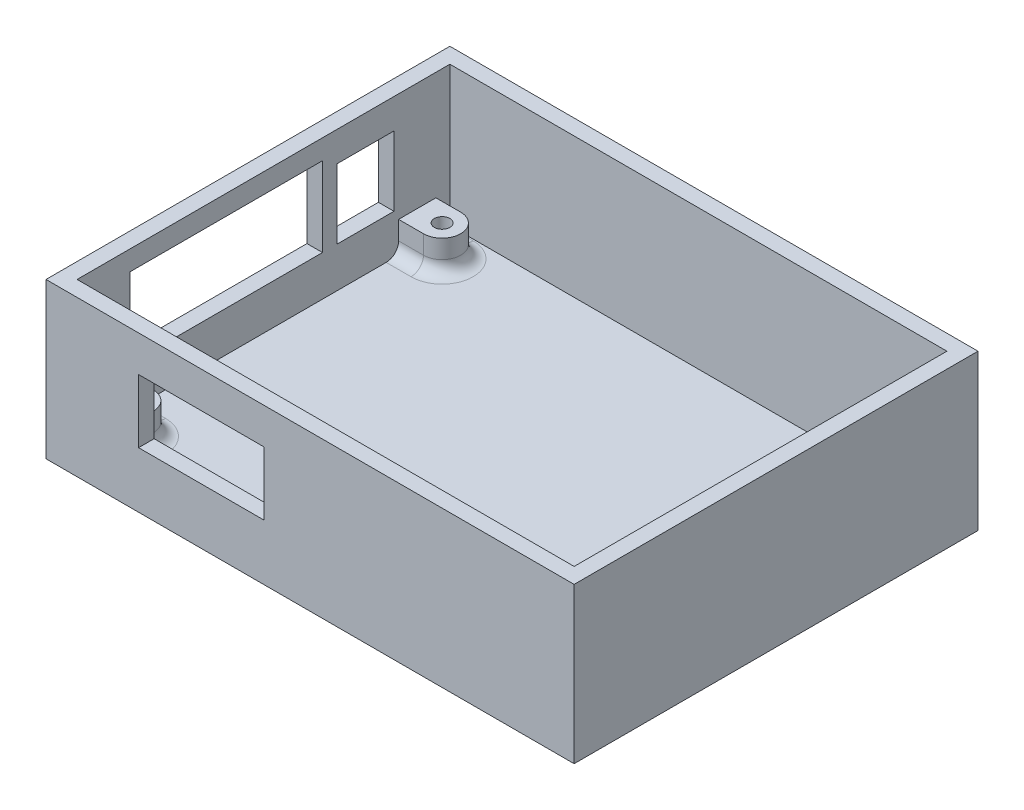
from build123d import *

# Parameters (mm, degrees)
SKETCH_1_W          = 85
SKETCH_1_H          = 65
EXTRUDE_1_DEPTH     = 25
SHELL_1_T           = -2.5
SKETCH_2_R          = 3
SKETCH_2_R_2        = 1.25
EXTRUDE_2_DEPTH     = 5
SKETCH_3_W          = 20.2
SKETCH_3_H          = 10.2
CUT_EXTRUDE_1_DEPTH = 3.5
SKETCH_4_W          = 9.2
SKETCH_4_H          = 11.2
SKETCH_4_W_2        = 31
SKETCH_4_H_2        = 12.8
CUT_EXTRUDE_2_DEPTH = 3.5
FILLET_1_R          = 2


with BuildPart() as part:
    # 草图1 → 凸台-拉伸1 (new body)
    with BuildSketch(Plane(origin=(0, 0, 0), x_dir=(1, 0, 0), z_dir=(0, 1, 0))):
        Rectangle(SKETCH_1_W, SKETCH_1_H)
    extrude(amount=EXTRUDE_1_DEPTH)

    # 抽壳1
    shell_1_openings = [part.faces().sort_by_distance(p)[0] for p in [
        (0, 25, 0),
    ]]
    offset(amount=SHELL_1_T, openings=shell_1_openings, kind=Kind.INTERSECTION)

    # 草图2 → 凸台-拉伸2 (add)
    with BuildSketch(Plane(origin=(0, 2.5, 0), x_dir=(1, 0, 0), z_dir=(0, 1, 0))):
        with Locations((32.25, 24.75)):
            Circle(SKETCH_2_R)
        with Locations((32.25, 24.75)):
            Circle(SKETCH_2_R_2, mode=Mode.SUBTRACT)
        with Locations((32.25, -24.75)):
            Circle(SKETCH_2_R)
        with Locations((32.25, -24.75)):
            Circle(SKETCH_2_R_2, mode=Mode.SUBTRACT)
        with BuildLine():
            Line((-36, 27.75), (-40, 27.75))
            Line((-40, 27.75), (-40, 21.75))
            Line((-40, 21.75), (-36, 21.75))
            ThreePointArc((-36, 21.75), (-33, 24.75), (-36, 27.75))
        make_face()
        with Locations((-36, 24.75)):
            Circle(SKETCH_2_R_2, mode=Mode.SUBTRACT)
        with BuildLine():
            Line((-36, -21.75), (-40, -21.75))
            Line((-40, -21.75), (-40, -27.75))
            Line((-40, -27.75), (-36, -27.75))
            ThreePointArc((-36, -27.75), (-33, -24.75), (-36, -21.75))
        make_face()
        with Locations((-36, -24.75)):
            Circle(SKETCH_2_R_2, mode=Mode.SUBTRACT)
    extrude(amount=EXTRUDE_2_DEPTH)

    # 草图3 → 切除-拉伸1 (cut, through all)
    with BuildSketch(Plane(origin=(0, 0, 30), x_dir=(-1, 0, 0), z_dir=(0, 0, -1))):
        with Locations((17.5, 14.1)):
            Rectangle(SKETCH_3_W, SKETCH_3_H)
    extrude(amount=-CUT_EXTRUDE_1_DEPTH, mode=Mode.SUBTRACT)

    # 草图4 → 切除-拉伸2 (cut, through all)
    with BuildSketch(Plane(origin=(-40, 0, 0), x_dir=(0, 0, -1), z_dir=(1, 0, 0))):
        with Locations((16.4, 14.6)):
            Rectangle(SKETCH_4_W, SKETCH_4_H)
        with Locations((-6, 15.4)):
            Rectangle(SKETCH_4_W_2, SKETCH_4_H_2)
    extrude(amount=-CUT_EXTRUDE_2_DEPTH, mode=Mode.SUBTRACT)

    # 圆角1
    fillet_1_edges = [part.edges().sort_by_distance(p)[0] for p in [
        (29.25, 2.5, -24.75),
        (29.25, 2.5, 24.75),
        (-33, 2.5, -24.75),
        (-38, 2.5, -27.75),
        (-38, 2.5, -21.75),
        (-33, 2.5, 24.75),
        (-38, 2.5, 21.75),
        (-38, 2.5, 27.75),
    ]]
    fillet(fillet_1_edges, radius=FILLET_1_R)


solid = part.part
